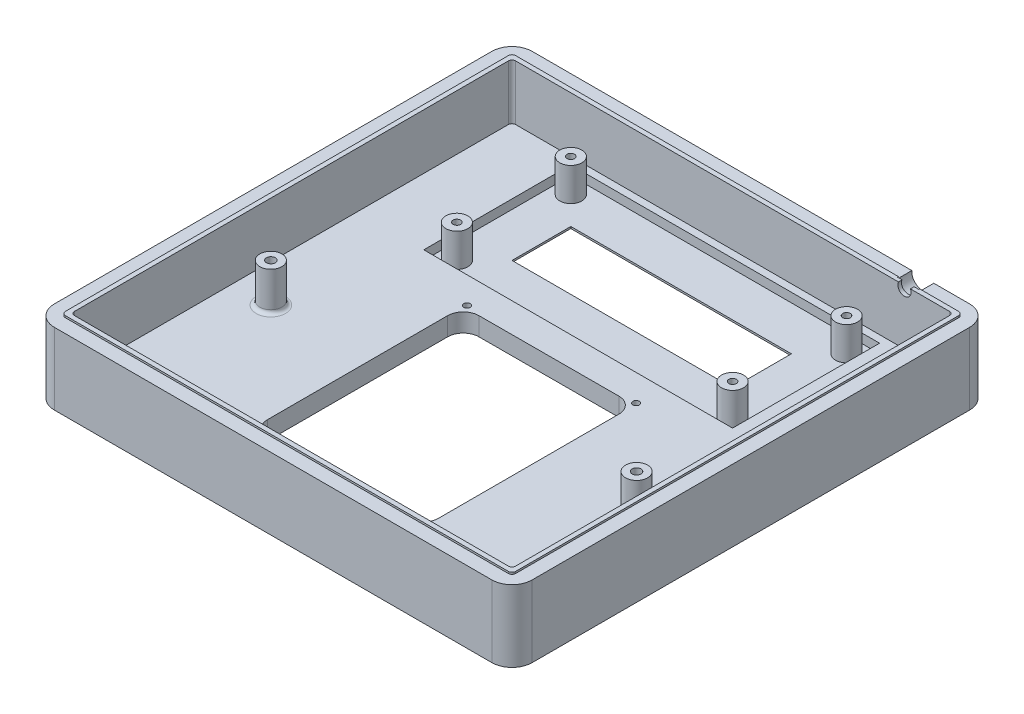
from build123d import *

# Parameters (mm, degrees)
BOSS_EXTRUDE2_DEPTH = 20
SKETCH5_W           = 120
SKETCH5_H           = 120
CUT_EXTRUDE1_DEPTH  = 15
FILLET2_R           = 1
FILLET3_R           = 1
FILLET4_R           = 1
FILLET5_R           = 1
CUT_EXTRUDE2_DEPTH  = 5
SKETCH8_W           = 60
SKETCH8_H           = 16
CUT_EXTRUDE5_DEPTH  = 5
SKETCH9_W           = 84
SKETCH9_H           = 40
CUT_EXTRUDE6_DEPTH  = 2.5
SKETCH10_R          = 3
BOSS_EXTRUDE3_DEPTH = 9
CHAMFER1_SIZE       = 2
CUT_EXTRUDE11_DEPTH = 5
CUT_EXTRUDE12_DEPTH = 4
SKETCH17_R          = 3
BOSS_EXTRUDE4_DEPTH = 10.54
SKETCH20_W          = 122.5
SKETCH20_H          = 122.5
CUT_EXTRUDE15_DEPTH = 0.5
FILLET7_R           = 1
FILLET8_R           = 1
FILLET9_R           = 1
FILLET10_R          = 1
SKETCH19_R          = 1.2
CUT_EXTRUDE20_DEPTH = 6
SKETCH18_R          = 1.2
CUT_EXTRUDE21_DEPTH = 6
SKETCH11_R          = 1.025
CUT_EXTRUDE22_DEPTH = 6
SKETCH13_R          = 1.025
CUT_EXTRUDE23_DEPTH = 6
SKETCH12_R          = 1.025
CUT_EXTRUDE24_DEPTH = 6
SKETCH14_R          = 1.025
CUT_EXTRUDE25_DEPTH = 6
SKETCH24_R          = 0.875
CUT_EXTRUDE28_DEPTH = 3
FILLET11_R          = 1
FILLET12_R          = 1


with BuildPart() as part:
    # Sketch4 → Boss-Extrude2 (new body)
    with BuildSketch(Plane(origin=(0, 0, 0), x_dir=(1, 0, 0), z_dir=(0, 1, 0))):
        with BuildLine():
            Line((-59.5, 65), (59.5, 65))
            ThreePointArc((59.5, 65), (63.389087297, 63.389087297), (65, 59.5))
            Line((65, 59.5), (65, -59.5))
            ThreePointArc((65, -59.5), (63.389087297, -63.389087297), (59.5, -65))
            Line((59.5, -65), (-59.5, -65))
            ThreePointArc((-59.5, -65), (-63.389087297, -63.389087297), (-65, -59.5))
            Line((-65, -59.5), (-65, 59.5))
            ThreePointArc((-65, 59.5), (-63.389087297, 63.389087297), (-59.5, 65))
        make_face()
    extrude(amount=BOSS_EXTRUDE2_DEPTH)

    # Sketch5 → Cut-Extrude1 (cut)
    with BuildSketch(Plane(origin=(0, 20, 0), x_dir=(1, 0, 0), z_dir=(0, 1, 0))):
        Rectangle(SKETCH5_W, SKETCH5_H)
    extrude(amount=-CUT_EXTRUDE1_DEPTH, mode=Mode.SUBTRACT)

    # Fillet2
    fillet2_edges = [part.edges().sort_by_distance(p)[0] for p in [
        (-60, 12.5, -60),
    ]]
    fillet(fillet2_edges, radius=FILLET2_R)

    # Fillet3
    fillet3_edges = [part.edges().sort_by_distance(p)[0] for p in [
        (60, 12.5, -60),
    ]]
    fillet(fillet3_edges, radius=FILLET3_R)

    # Fillet4
    fillet4_edges = [part.edges().sort_by_distance(p)[0] for p in [
        (-60, 12.5, 60),
    ]]
    fillet(fillet4_edges, radius=FILLET4_R)

    # Fillet5
    fillet5_edges = [part.edges().sort_by_distance(p)[0] for p in [
        (60, 12.5, 60),
    ]]
    fillet(fillet5_edges, radius=FILLET5_R)

    # Sketch6 → Cut-Extrude2 (cut)
    with BuildSketch(Plane(origin=(0, 5, 0), x_dir=(1, 0, 0), z_dir=(0, 1, 0))):
        with BuildLine():
            Line((-19, 10), (19, 10.074775785))
            ThreePointArc((19, 10.074775785), (22.00520382, 8.829979605), (23.25, 5.824775785))
            Line((23.25, 5.824775785), (23.25, -43.25))
            ThreePointArc((23.25, -43.25), (22.00520382, -46.25520382), (19, -47.5))
            Line((19, -47.5), (-19, -47.5))
            ThreePointArc((-19, -47.5), (-22.00520382, -46.25520382), (-23.25, -43.25))
            Line((-23.25, -43.25), (-23.25, 5.75))
            ThreePointArc((-23.25, 5.75), (-22.00520382, 8.75520382), (-19, 10))
        make_face()
    extrude(amount=-CUT_EXTRUDE2_DEPTH, mode=Mode.SUBTRACT)

    # Sketch8 → Cut-Extrude5 (cut)
    with BuildSketch(Plane(origin=(0, 5, 0), x_dir=(1, 0, 0), z_dir=(0, 1, 0))):
        with Locations((0, 38)):
            Rectangle(SKETCH8_W, SKETCH8_H)
    extrude(amount=-CUT_EXTRUDE5_DEPTH, mode=Mode.SUBTRACT)

    # Sketch9 → Cut-Extrude6 (cut)
    with BuildSketch(Plane(origin=(0, 5, 0), x_dir=(1, 0, 0), z_dir=(0, 1, 0))):
        with Locations((0, 38)):
            Rectangle(SKETCH9_W, SKETCH9_H)
    extrude(amount=-CUT_EXTRUDE6_DEPTH, mode=Mode.SUBTRACT)

    # Sketch10 → Boss-Extrude3 (add)
    with BuildSketch(Plane(origin=(0, 2.5, 0), x_dir=(1, 0, 0), z_dir=(0, 1, 0))):
        with Locations((37.5, 53.5)):
            Circle(SKETCH10_R)
        with Locations((-37.5, 53.5)):
            Circle(SKETCH10_R)
        with Locations((-37.5, 22.5)):
            Circle(SKETCH10_R)
        with Locations((37.5, 22.5)):
            Circle(SKETCH10_R)
    extrude(amount=BOSS_EXTRUDE3_DEPTH)

    # Chamfer1
    chamfer1_edges = [part.edges().sort_by_distance(p)[0] for p in [
        (30, 0, -38),
        (0, 0, -30),
        (-30, 0, -38),
        (0, 0, -46),
    ]]
    chamfer(chamfer1_edges, length=CHAMFER1_SIZE)

    # Sketch15 → Cut-Extrude11 (cut)
    with BuildSketch(Plane(origin=(0, 0, -65), x_dir=(-1, 0, 0), z_dir=(0, 0, -1))):
        with BuildLine():
            Line((-45.118313756, 20), (-48.381686244, 20))
            ThreePointArc((-48.381686244, 20), (-46.75, 17.44), (-45.118313756, 20))
        make_face()
    extrude(amount=-CUT_EXTRUDE11_DEPTH, mode=Mode.SUBTRACT)

    # Sketch16 → Cut-Extrude12 (cut)
    with BuildSketch(Plane(origin=(0, 0, -65), x_dir=(-1, 0, 0), z_dir=(0, 0, -1))):
        with BuildLine():
            Line((-43.847862856, 20), (-49.652137144, 20))
            ThreePointArc((-49.652137144, 20), (-46.75, 16.24), (-43.847862856, 20))
        make_face()
    extrude(amount=-CUT_EXTRUDE12_DEPTH, mode=Mode.SUBTRACT)

    # Sketch17 → Boss-Extrude4 (add)
    with BuildSketch(Plane(origin=(0, 5, 0), x_dir=(1, 0, 0), z_dir=(0, 1, 0))):
        with Locations((49.7, -15.8)):
            Circle(SKETCH17_R)
        with Locations((-49.8, -15.8)):
            Circle(SKETCH17_R)
    extrude(amount=BOSS_EXTRUDE4_DEPTH)

    # Sketch20 → Cut-Extrude15 (cut)
    with BuildSketch(Plane(origin=(0, 20, 0), x_dir=(1, 0, 0), z_dir=(0, 1, 0))):
        with BuildLine():
            Line((-59.5, -65), (59.5, -65))
            ThreePointArc((59.5, -65), (63.389087297, -63.389087297), (65, -59.5))
            Line((65, -59.5), (65, 59.5))
            ThreePointArc((65, 59.5), (63.389087297, 63.389087297), (59.5, 65))
            Line((59.5, 65), (-59.5, 65))
            ThreePointArc((-59.5, 65), (-63.389087297, 63.389087297), (-65, 59.5))
            Line((-65, 59.5), (-65, -59.5))
            ThreePointArc((-65, -59.5), (-63.389087297, -63.389087297), (-59.5, -65))
        make_face()
        Rectangle(SKETCH20_W, SKETCH20_H, mode=Mode.SUBTRACT)
    extrude(amount=-CUT_EXTRUDE15_DEPTH, mode=Mode.SUBTRACT)

    # Fillet7
    fillet7_edges = [part.edges().sort_by_distance(p)[0] for p in [
        (61.25, 19.75, 61.25),
    ]]
    fillet(fillet7_edges, radius=FILLET7_R)

    # Fillet8
    fillet8_edges = [part.edges().sort_by_distance(p)[0] for p in [
        (-61.25, 19.75, 61.25),
    ]]
    fillet(fillet8_edges, radius=FILLET8_R)

    # Fillet9
    fillet9_edges = [part.edges().sort_by_distance(p)[0] for p in [
        (-61.25, 19.75, -61.25),
    ]]
    fillet(fillet9_edges, radius=FILLET9_R)

    # Fillet10
    fillet10_edges = [part.edges().sort_by_distance(p)[0] for p in [
        (61.25, 19.75, -61.25),
    ]]
    fillet(fillet10_edges, radius=FILLET10_R)

    # Sketch19 → Cut-Extrude20 (cut)
    with BuildSketch(Plane(origin=(0, 15.54, 0), x_dir=(1, 0, 0), z_dir=(0, 1, 0))):
        with Locations((49.7, -15.8)):
            Circle(SKETCH19_R)
    extrude(amount=-CUT_EXTRUDE20_DEPTH, mode=Mode.SUBTRACT)

    # Sketch18 → Cut-Extrude21 (cut)
    with BuildSketch(Plane(origin=(0, 15.54, 0), x_dir=(1, 0, 0), z_dir=(0, 1, 0))):
        with Locations((-49.8, -15.8)):
            Circle(SKETCH18_R)
    extrude(amount=-CUT_EXTRUDE21_DEPTH, mode=Mode.SUBTRACT)

    # Sketch11 → Cut-Extrude22 (cut)
    with BuildSketch(Plane(origin=(0, 11.5, 0), x_dir=(1, 0, 0), z_dir=(0, 1, 0))):
        with Locations((-37.5, 53.5)):
            Circle(SKETCH11_R)
    extrude(amount=-CUT_EXTRUDE22_DEPTH, mode=Mode.SUBTRACT)

    # Sketch13 → Cut-Extrude23 (cut)
    with BuildSketch(Plane(origin=(0, 11.5, 0), x_dir=(1, 0, 0), z_dir=(0, 1, 0))):
        with Locations((37.5, 53.5)):
            Circle(SKETCH13_R)
    extrude(amount=-CUT_EXTRUDE23_DEPTH, mode=Mode.SUBTRACT)

    # Sketch12 → Cut-Extrude24 (cut)
    with BuildSketch(Plane(origin=(0, 11.5, 0), x_dir=(1, 0, 0), z_dir=(0, 1, 0))):
        with Locations((-37.5, 22.5)):
            Circle(SKETCH12_R)
    extrude(amount=-CUT_EXTRUDE24_DEPTH, mode=Mode.SUBTRACT)

    # Sketch14 → Cut-Extrude25 (cut)
    with BuildSketch(Plane(origin=(0, 11.5, 0), x_dir=(1, 0, 0), z_dir=(0, 1, 0))):
        with Locations((37.5, 22.5)):
            Circle(SKETCH14_R)
    extrude(amount=-CUT_EXTRUDE25_DEPTH, mode=Mode.SUBTRACT)

    # Sketch24 → Cut-Extrude28 (cut)
    with BuildSketch(Plane(origin=(0, 5, 0), x_dir=(1, 0, 0), z_dir=(0, 1, 0))):
        with Locations((23, 10.768693946)):
            Circle(SKETCH24_R)
        with Locations((-23, 10.768693946)):
            Circle(SKETCH24_R)
        with Locations((-23, -48.231306054)):
            Circle(SKETCH24_R)
        with Locations((23, -48.231306054)):
            Circle(SKETCH24_R)
    extrude(amount=-CUT_EXTRUDE28_DEPTH, mode=Mode.SUBTRACT)

    # Fillet11
    fillet11_edges = [part.edges().sort_by_distance(p)[0] for p in [
        (-52.8, 5, 15.8),
    ]]
    fillet(fillet11_edges, radius=FILLET11_R)

    # Fillet12
    fillet12_edges = [part.edges().sort_by_distance(p)[0] for p in [
        (46.7, 5, 15.8),
    ]]
    fillet(fillet12_edges, radius=FILLET12_R)


solid = part.part
